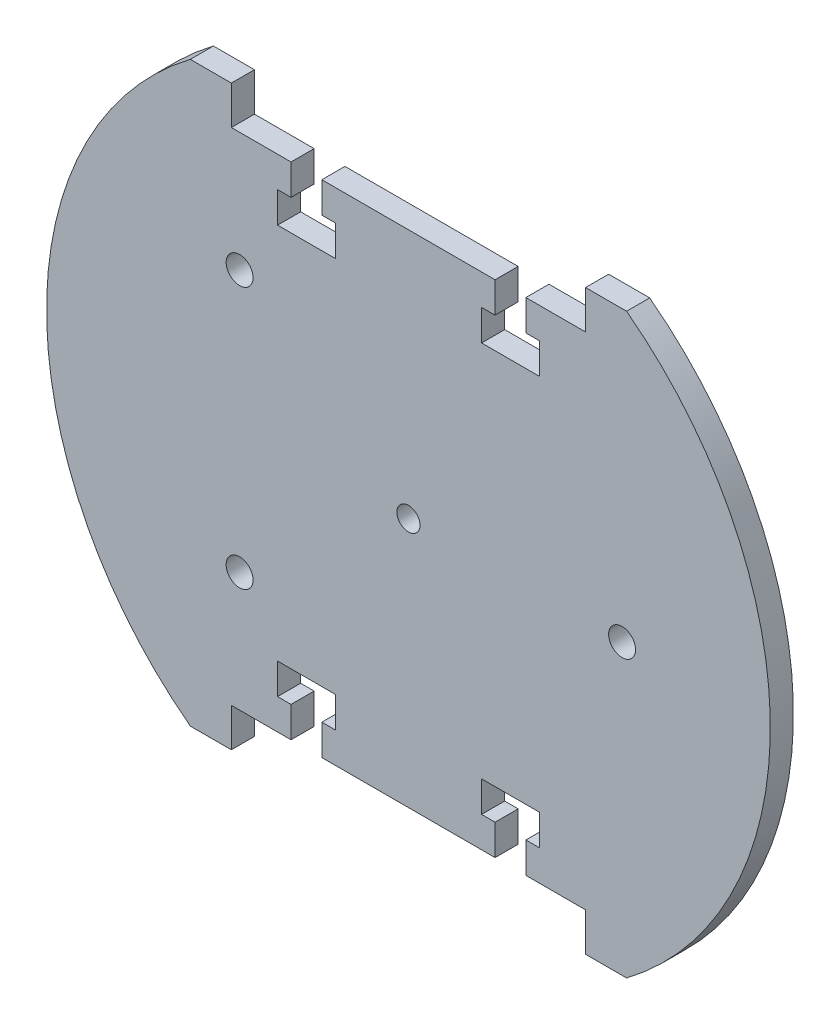
from build123d import *

# Parameters (mm, degrees)
SKETCH8_R           = 3.5
SKETCH8_R_2         = 3
BOSS_EXTRUDE3_DEPTH = 6


with BuildPart() as part:
    # Sketch8 → Boss-Extrude3 (new body)
    with BuildSketch(Plane.XY):
        with BuildLine():
            Line((-56.665686266, -75), (-46, -75))
            Line((-46, -75), (-46, -65))
            Line((-46, -65), (-30.5, -65))
            Line((-30.5, -65), (-30.5, -57.029309822))
            Line((-30.5, -57.029309822), (-34, -57.029309822))
            Line((-34, -57.029309822), (-34, -49.029309822))
            Line((-34, -49.029309822), (-19, -49.029309822))
            Line((-19, -49.029309822), (-19, -57.029309822))
            Line((-19, -57.029309822), (-22.5, -57.029309822))
            Line((-22.5, -57.029309822), (-22.5, -65))
            Line((-22.5, -65), (22.5, -65))
            Line((22.5, -65), (22.5, -57.029309822))
            Line((22.5, -57.029309822), (19, -57.029309822))
            Line((19, -57.029309822), (19, -49.029309822))
            Line((19, -49.029309822), (34, -49.029309822))
            Line((34, -49.029309822), (34, -57.029309822))
            Line((34, -57.029309822), (30.5, -57.029309822))
            Line((30.5, -57.029309822), (30.5, -65))
            Line((30.5, -65), (46, -65))
            Line((46, -65), (46, -75))
            Line((46, -75), (56.665686266, -75))
            ThreePointArc((56.665686266, -75), (94, 0), (56.665686266, 75))
            Line((56.665686266, 75), (46, 75))
            Line((46, 75), (46, 65))
            Line((46, 65), (30.5, 65))
            Line((30.5, 65), (30.5, 57.029309822))
            Line((30.5, 57.029309822), (34, 57.029309822))
            Line((34, 57.029309822), (34, 49.029309822))
            Line((34, 49.029309822), (19, 49.029309822))
            Line((19, 49.029309822), (19, 57.029309822))
            Line((19, 57.029309822), (22.5, 57.029309822))
            Line((22.5, 57.029309822), (22.5, 65))
            Line((22.5, 65), (-22.5, 65))
            Line((-22.5, 65), (-22.5, 57.029309822))
            Line((-22.5, 57.029309822), (-19, 57.029309822))
            Line((-19, 57.029309822), (-19, 49.029309822))
            Line((-19, 49.029309822), (-34, 49.029309822))
            Line((-34, 49.029309822), (-34, 57.029309822))
            Line((-34, 57.029309822), (-30.5, 57.029309822))
            Line((-30.5, 57.029309822), (-30.5, 65))
            Line((-30.5, 65), (-46, 65))
            Line((-46, 65), (-46, 75))
            Line((-46, 75), (-56.665686266, 75))
            ThreePointArc((-56.665686266, 75), (-94, 0), (-56.665686266, -75))
        make_face()
        with Locations((-43.86, 34)):
            Circle(SKETCH8_R, mode=Mode.SUBTRACT)
        with Locations((55.5, 0)):
            Circle(SKETCH8_R, mode=Mode.SUBTRACT)
        with Locations((-43.86, -34)):
            Circle(SKETCH8_R, mode=Mode.SUBTRACT)
        Circle(SKETCH8_R_2, mode=Mode.SUBTRACT)
    extrude(amount=BOSS_EXTRUDE3_DEPTH)


solid = part.part
